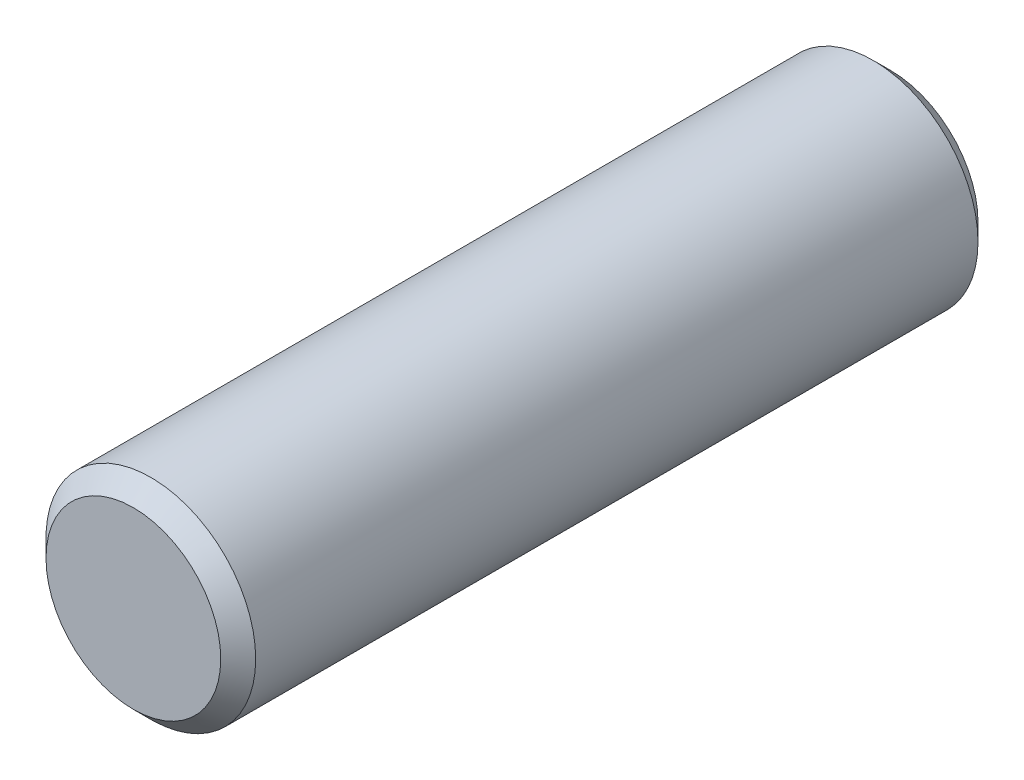
from build123d import *

# Parameters (mm, degrees)
ESQUISSE1_R        = 9
BOSS_EXTRU_1_DEPTH = 32.5
CHANFREIN1_SIZE    = 1.5


with BuildPart() as part:
    # Esquisse1 → Boss.-Extru.1 (new body, symmetric)
    with BuildSketch(Plane.XY):
        Circle(ESQUISSE1_R)
    extrude(amount=BOSS_EXTRU_1_DEPTH, both=True)

    # Chanfrein1
    chanfrein1_edges = [part.edges().sort_by_distance(p)[0] for p in [
        (-9, 0, -32.5),
        (-9, 0, 32.5),
    ]]
    chamfer(chanfrein1_edges, length=CHANFREIN1_SIZE)


solid = part.part
